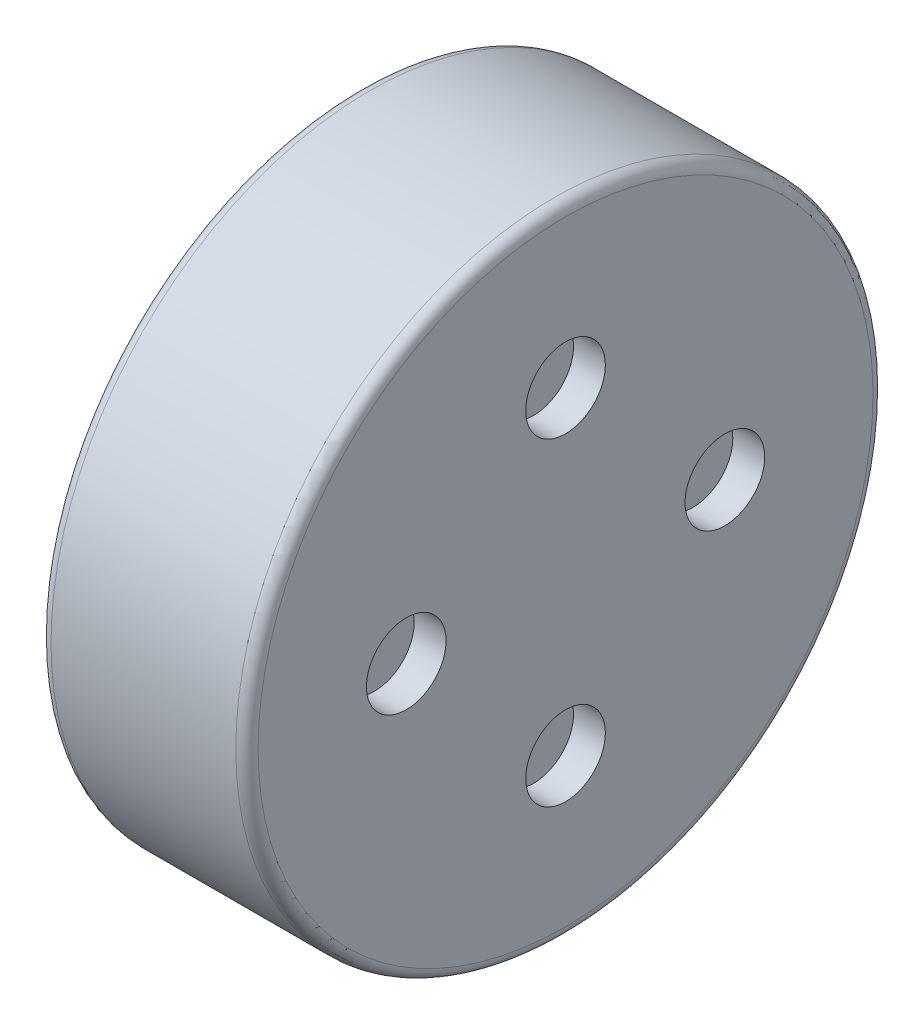
from build123d import *

# Parameters (mm, degrees)
SKETCH2_R           = 0.9
CUT_EXTRUDE1_DEPTH  = 0.05
SKETCH3_R           = 0.6
BOSS_EXTRUDE1_DEPTH = 0.05
SKETCH4_R           = 0.275
BOSS_EXTRUDE2_DEPTH = 0.08
SKETCH5_W           = 0.08
SKETCH5_H           = 0.2
SKETCH6_W           = 0.08
SKETCH6_H           = 0.2
SKETCH7_W           = 0.08
SKETCH7_H           = 0.2
SKETCH8_W           = 0.08
SKETCH8_H           = 0.2
SKETCH9_W           = 0.08
SKETCH9_H           = 0.2
HOLE1_D             = 0.5
HOLE1_DEPTH         = 0.2
FILLET1_R           = 0.07


with BuildPart() as part:
    # Sketch1 → Revolve1 (revolve)
    with BuildSketch(Plane(origin=(0, 0, 0), x_dir=(-1, 0, 0), z_dir=(0, 0, -1))):
        with BuildLine():
            Line((-1.3, 2), (-1.3, 0))
            Line((-1.3, 0), (-0.03, 0))
            Line((-0.03, 0), (-0.03, 1.8))
            Line((-0.03, 1.8), (-0.05, 1.8))
            ThreePointArc((-0.05, 1.8), (-0.014644661, 1.814644661), (0, 1.85))
            Line((0, 1.85), (0, 2))
            Line((0, 2), (-1.3, 2))
        make_face()
    revolve(axis=Axis((1.3, 0, 0), (-1, 0, 0)))

    # Sketch2 → Cut-Extrude1 (cut)
    with BuildSketch(Plane.ZY.offset(-0.03)):
        Circle(SKETCH2_R)
    extrude(amount=-CUT_EXTRUDE1_DEPTH, mode=Mode.SUBTRACT)

    # Sketch3 → Boss-Extrude1 (add)
    with BuildSketch(Plane.ZY.offset(-0.08)):
        Circle(SKETCH3_R)
    extrude(amount=BOSS_EXTRUDE1_DEPTH)

    # Sketch4 → Boss-Extrude2 (add)
    with BuildSketch(Plane.ZY.offset(-0.03)):
        Circle(SKETCH4_R)
    extrude(amount=BOSS_EXTRUDE2_DEPTH)

    # Sketch5 → Revolve2 (revolve)
    with BuildSketch(Plane(origin=(0, 0, -1.15), x_dir=(-1, 0, 0), z_dir=(0, 0, -1))):
        with Locations((0.01, 0.1)):
            Rectangle(SKETCH5_W, SKETCH5_H)
    revolve(axis=Axis((0.03, 0, -1.15), (-1, 0, 0)))

    # Sketch6 → Revolve3 (revolve)
    with BuildSketch(Plane(origin=(0, 0, -0.355369544), x_dir=(-1, 0, 0), z_dir=(0, 0, -1))):
        with Locations((0.01, 1.193714994)):
            Rectangle(SKETCH6_W, SKETCH6_H)
    revolve(axis=Axis((0.03, 1.093714994, -0.355369544), (-1, 0, 0)))

    # Sketch7 → Revolve4 (revolve)
    with BuildSketch(Plane(origin=(0, 0, 0.930369544), x_dir=(-1, 0, 0), z_dir=(0, 0, -1))):
        with Locations((0.01, 0.77595304)):
            Rectangle(SKETCH7_W, SKETCH7_H)
    revolve(axis=Axis((0.03, 0.67595304, 0.930369544), (-1, 0, 0)))

    # Sketch8 → Revolve5 (revolve)
    with BuildSketch(Plane(origin=(0, 0, 0.930369544), x_dir=(-1, 0, 0), z_dir=(0, 0, -1))):
        with Locations((0.01, -0.57595304)):
            Rectangle(SKETCH8_W, SKETCH8_H)
    revolve(axis=Axis((0.03, -0.67595304, 0.930369544), (-1, 0, 0)))

    # Sketch9 → Revolve6 (revolve)
    with BuildSketch(Plane(origin=(0, 0, -0.355369544), x_dir=(-1, 0, 0), z_dir=(0, 0, -1))):
        with Locations((0.01, -0.993714994)):
            Rectangle(SKETCH9_W, SKETCH9_H)
    revolve(axis=Axis((0.03, -1.093714994, -0.355369544), (-1, 0, 0)))

    # Hole1
    with Locations(Plane(origin=(1.3, 0, 0), x_dir=(0, 0, -1), z_dir=(1, 0, 0))):
        with Locations((-1, 0), (0, -1), (1, 0), (0, 1)):
            Hole(HOLE1_D / 2, depth=HOLE1_DEPTH)

    # Fillet1
    fillet1_edges = [part.edges().sort_by_distance(p)[0] for p in [
        (-0.05, 0, -0.275),
        (-0.05, -0.2, -1.15),
        (-0.05, 0.893714994, -0.355369544),
        (-0.05, 0.47595304, 0.930369544),
        (-0.05, -0.87595304, 0.930369544),
        (-0.05, -1.293714994, -0.355369544),
        (0, -2, 0),
        (1.3, -2, 0),
    ]]
    fillet(fillet1_edges, radius=FILLET1_R)


solid = part.part
